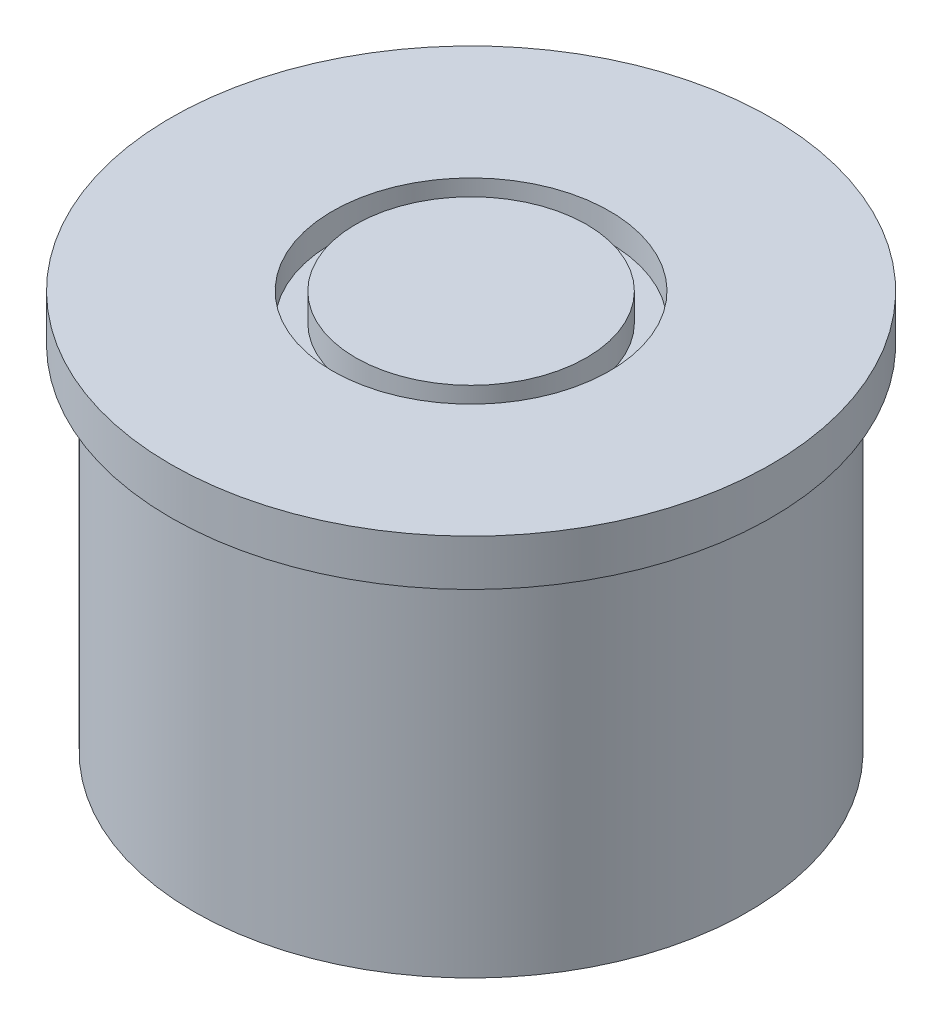
from build123d import *

# Parameters (mm, degrees)
SKETCH1_R            = 30
BOSS_EXTRUDE8_DEPTH  = 43.19
SKETCH1_9_R          = 32.5
SKETCH1_9_R_2        = 30
BOSS_EXTRUDE10_DEPTH = 5
SKETCH2_R            = 8
SKETCH2_R_2          = 6
CUT_EXTRUDE1_DEPTH   = 2
SKETCH3_R            = 15
SKETCH3_R_2          = 12.5
CUT_EXTRUDE2_DEPTH   = 3


with BuildPart() as part:
    # Sketch1 → Boss-Extrude8 (new body)
    with BuildSketch(Plane(origin=(0, 0, 0), x_dir=(1, 0, 0), z_dir=(0, 1, 0))):
        Circle(SKETCH1_R)
    extrude(amount=-BOSS_EXTRUDE8_DEPTH)

    # Sketch1_9 → Boss-Extrude10 (add)
    with BuildSketch(Plane(origin=(0, 0, 0), x_dir=(1, 0, 0), z_dir=(0, 1, 0))):
        Circle(SKETCH1_9_R)
        Circle(SKETCH1_9_R_2, mode=Mode.SUBTRACT)
    extrude(amount=-BOSS_EXTRUDE10_DEPTH)

    # Sketch2 → Cut-Extrude1 (cut)
    with BuildSketch(Plane.XZ.offset(43.19)):
        Circle(SKETCH2_R)
        Circle(SKETCH2_R_2, mode=Mode.SUBTRACT)
    extrude(amount=-CUT_EXTRUDE1_DEPTH, mode=Mode.SUBTRACT)

    # Sketch3 → Cut-Extrude2 (cut)
    with BuildSketch(Plane(origin=(0, 0, 0), x_dir=(1, 0, 0), z_dir=(0, 1, 0))):
        Circle(SKETCH3_R)
        Circle(SKETCH3_R_2, mode=Mode.SUBTRACT)
    extrude(amount=-CUT_EXTRUDE2_DEPTH, mode=Mode.SUBTRACT)


solid = part.part
